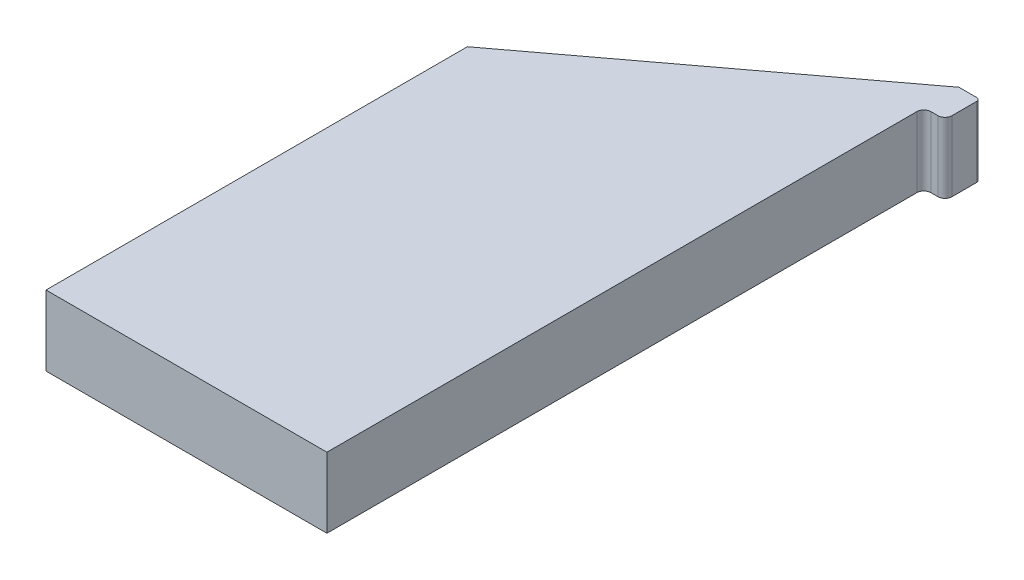
from build123d import *

# Parameters (mm, degrees)
BOSS_EXTRUDE4_DEPTH = 5
BOSS_EXTRUDE5_DEPTH = 5


with BuildPart() as part:
    # Sketch4 → Boss-Extrude4 (new body)
    with BuildSketch(Plane(origin=(0, 0, 0), x_dir=(1, 0, 0), z_dir=(0, 1, 0))):
        Polygon((-10, 15), (10, 30), (10, 15), (10, -15), (-10, -15), align=None)
    extrude(amount=BOSS_EXTRUDE4_DEPTH)

    # Sketch6 → Boss-Extrude5 (add)
    with BuildSketch(Plane(origin=(0, 5, 0), x_dir=(1, 0, 0), z_dir=(0, 1, 0))):
        with BuildLine():
            Line((10, 30), (11.25, 30))
            ThreePointArc((11.25, 30), (11.426776695, 29.926776695), (11.5, 29.75))
            Line((11.5, 29.75), (11.5, 28))
            ThreePointArc((11.5, 28), (11.353553391, 27.646446609), (11, 27.5))
            Line((11, 27.5), (10.5, 27.5))
            ThreePointArc((10.5, 27.5), (10.146446609, 27.353553391), (10, 27))
            Line((10, 27), (10, 30))
        make_face()
    extrude(amount=-BOSS_EXTRUDE5_DEPTH)


solid = part.part
